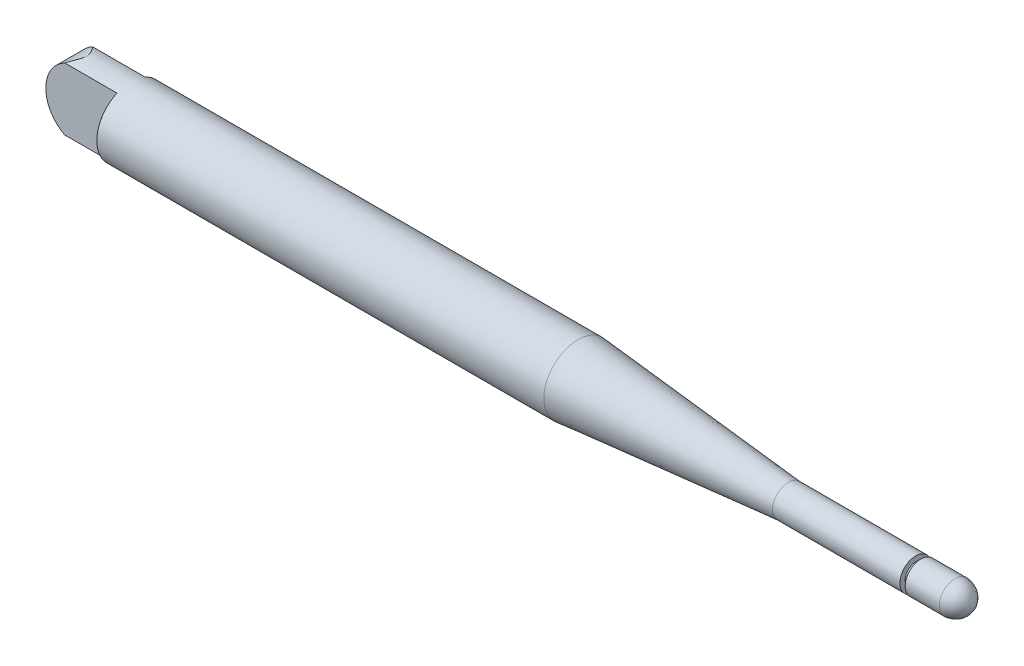
from build123d import *

# Parameters (mm, degrees)
BOSS_EXTRUDE1_DEPTH = 13.5
CUT_EXTRUDE1_DEPTH  = 13.5


with BuildPart() as part:
    # Sketch1 → Revolve1 (revolve)
    with BuildSketch(Plane.XY):
        with BuildLine():
            Line((0, 0), (0, -6.5))
            Line((0, -6.5), (85, -6.5))
            Line((85, -6.5), (125, -3))
            Line((125, -3), (149.222035298, -3))
            Line((149.222035298, -3), (149.222035298, -2))
            Line((149.222035298, -2), (150.222035298, -2))
            Line((150.222035298, -2), (150.222035298, -3))
            Line((150.222035298, -3), (156.707023179, -3))
            ThreePointArc((156.707023179, -3), (158.934336378, -2.137547522), (160, 0))
            Line((160, 0), (0, 0))
        make_face()
    revolve(axis=Axis((0, 0, 0), (1, 0, 0)))

    # Sketch2 → Boss-Extrude1 (add)
    with BuildSketch(Plane.ZY):
        with BuildLine():
            Line((-2.658777536, 5.931349089), (-2.658777536, -5.931349089))
            ThreePointArc((-2.658777536, -5.931349089), (0, -6.5), (2.658777536, -5.931349089))
            Line((2.658777536, -5.931349089), (2.658777536, 5.931349089))
            ThreePointArc((2.658777536, 5.931349089), (0, 6.5), (-2.658777536, 5.931349089))
        make_face()
    extrude(amount=BOSS_EXTRUDE1_DEPTH)

    # Sketch3 → Cut-Extrude1 (cut)
    with BuildSketch(Plane.XY.offset(2.658777536)):
        with BuildLine():
            Line((-7.271115967, 6.669291611), (-14.242543504, 7.619628139))
            Line((-14.242543504, 7.619628139), (-14.81279281, -7.656627724))
            Line((-14.81279281, -7.656627724), (-6.247435847, -8.529121085))
            Line((-6.247435847, -8.529121085), (-7.632896548, -6.659471856))
            ThreePointArc((-7.632896548, -6.659471856), (-13.535199526, 0.170025059), (-7.271115967, 6.669291611))
        make_face()
    extrude(amount=-CUT_EXTRUDE1_DEPTH, mode=Mode.SUBTRACT)


solid = part.part
